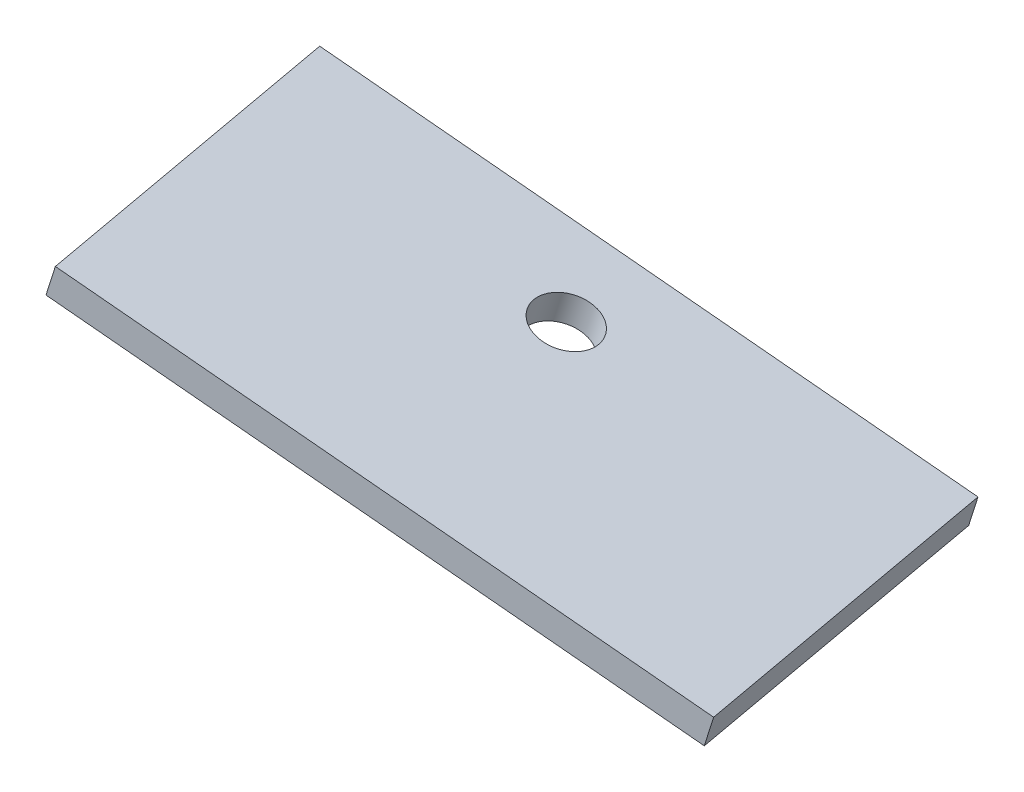
from build123d import *

# Parameters (mm, degrees)
BOSS_EXTRUDE1_DEPTH = 2
SKETCH2_R           = 2
CUT_EXTRUDE1_DEPTH  = 2


with BuildPart() as part:
    # Sketch1 → Boss-Extrude1 (new body)
    with BuildSketch(Plane(origin=(-2.914930538, -10.335344565, 0.528764089), x_dir=(0.96254631, -0.270763199, 0.013852451), z_dir=(-0.271117318, -0.961289082, 0.049180281))):
        Polygon((316.535932849, 476.010199203), (356.220286187, 468.521626673), (358.074594008, 478.348199957), (360.392478785, 490.631416562), (320.708125447, 498.119989092), (318.39024067, 485.836772487), align=None)
    extrude(amount=BOSS_EXTRUDE1_DEPTH)

    # Sketch2 → Cut-Extrude1 (cut)
    with BuildSketch(Plane(origin=(-3.457165175, -12.257922729, 0.627124651), x_dir=(0.96254631, -0.270763199, 0.013852451), z_dir=(-0.271117318, -0.961289082, 0.049180281))):
        with Locations((336.760137712, 478.299715406)):
            Circle(SKETCH2_R)
    extrude(amount=-CUT_EXTRUDE1_DEPTH, mode=Mode.SUBTRACT)


solid = part.part
